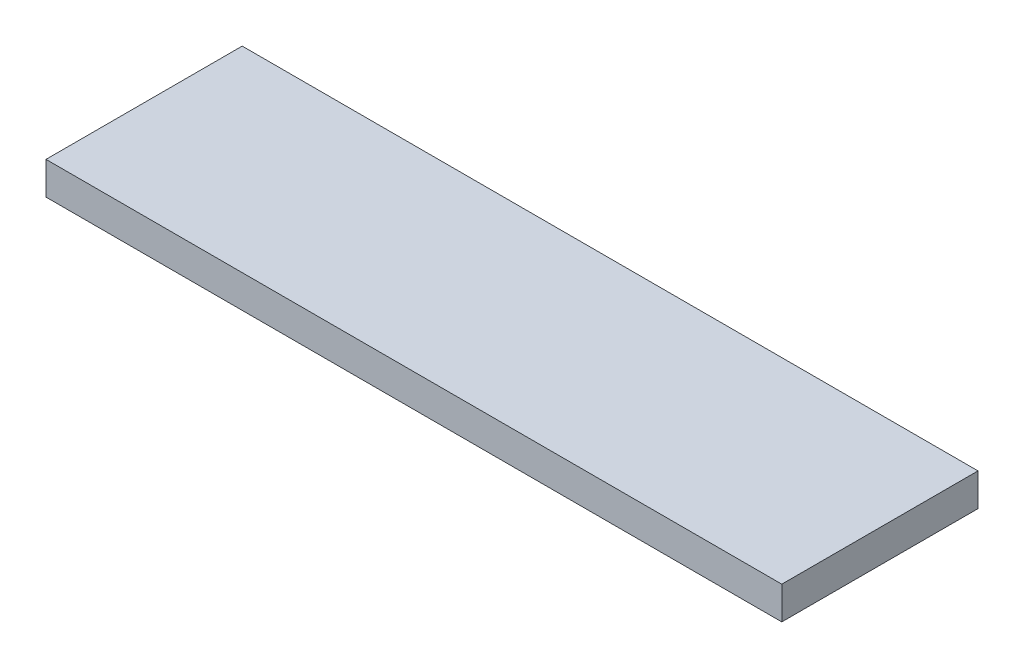
from build123d import *

# Parameters (mm, degrees)
SKETCH1_W           = 285.75
SKETCH1_H           = 76.2
BOSS_EXTRUDE1_DEPTH = 12.7


with BuildPart() as part:
    # Sketch1 → Boss-Extrude1 (new body)
    with BuildSketch(Plane(origin=(0, 0, 0), x_dir=(1, 0, 0), z_dir=(0, 1, 0))):
        with Locations((142.875, 38.1)):
            Rectangle(SKETCH1_W, SKETCH1_H)
    extrude(amount=BOSS_EXTRUDE1_DEPTH)


solid = part.part
